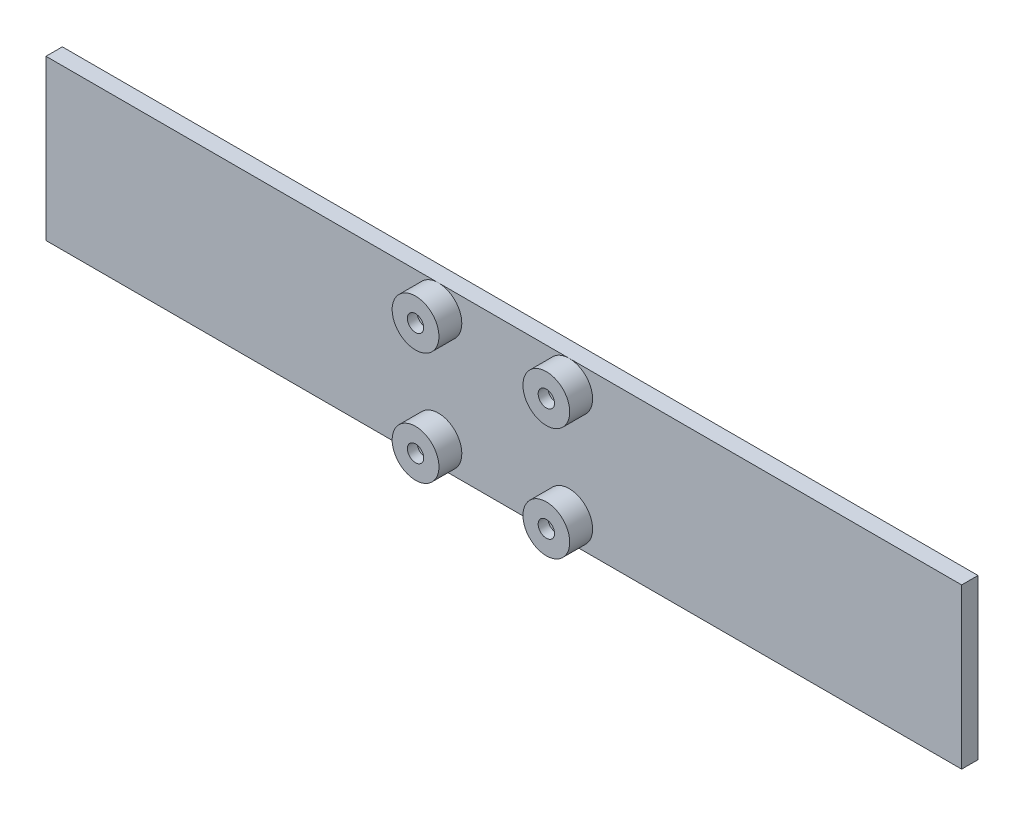
from build123d import *

# Parameters (mm, degrees)
SKETCH1_W           = 280
SKETCH1_H           = 48.8
BOSS_EXTRUDE1_DEPTH = 4
CUT_EXTRUDE1_DEPTH  = 5
SKETCH3_R           = 7.15
SKETCH3_R_2         = 5.25
BOSS_EXTRUDE2_DEPTH = 8
SKETCH4_R           = 7.15
SKETCH4_R_2         = 2.5
BOSS_EXTRUDE3_DEPTH = 3
SKETCH5_W           = 280
SKETCH5_H           = 48.8
BOSS_EXTRUDE6_DEPTH = 1
SKETCH6_R           = 5.25
CUT_EXTRUDE2_DEPTH  = 1


with BuildPart() as part:
    # Sketch1 → Boss-Extrude1 (new body)
    with BuildSketch(Plane.XY):
        with Locations((18.41484, 11.367285)):
            Rectangle(SKETCH1_W, SKETCH1_H)
    extrude(amount=BOSS_EXTRUDE1_DEPTH)

    # Sketch2 → Cut-Extrude1 (cut, through all)
    with BuildSketch(Plane.XY.offset(4)):
        with BuildLine():
            Line((-1.58516, 23.367285), (-1.58516, 28.617285))
            Line((-1.58516, 28.617285), (3.66484, 28.617285))
            ThreePointArc((3.66484, 28.617285), (-5.297471, 32.329596), (-1.58516, 23.367285))
        make_face()
        with BuildLine():
            Line((3.66484, 28.617285), (-1.58516, 28.617285))
            Line((-1.58516, 28.617285), (-1.58516, 23.367285))
            ThreePointArc((-1.58516, 23.367285), (2.12715, 24.904974), (3.66484, 28.617285))
        make_face()
        with BuildLine():
            ThreePointArc((3.66484, -5.882715), (2.12715, -2.170404), (-1.58516, -0.632715))
            Line((-1.58516, -0.632715), (-1.58516, -5.882715))
            Line((-1.58516, -5.882715), (3.66484, -5.882715))
        make_face()
        with BuildLine():
            Line((-1.58516, -5.882715), (-1.58516, -0.632715))
            ThreePointArc((-1.58516, -0.632715), (-5.297471, -9.595026), (3.66484, -5.882715))
            Line((3.66484, -5.882715), (-1.58516, -5.882715))
        make_face()
        with BuildLine():
            ThreePointArc((43.66484, -5.882715), (42.12715, -2.170404), (38.41484, -0.632715))
            Line((38.41484, -0.632715), (38.41484, -5.882715))
            Line((38.41484, -5.882715), (33.16484, -5.882715))
            ThreePointArc((33.16484, -5.882715), (38.41484, -11.132715), (43.66484, -5.882715))
        make_face()
        with BuildLine():
            Line((38.41484, -5.882715), (38.41484, -0.632715))
            ThreePointArc((38.41484, -0.632715), (34.702529, -2.170404), (33.16484, -5.882715))
            Line((33.16484, -5.882715), (38.41484, -5.882715))
        make_face()
        with BuildLine():
            ThreePointArc((43.66484, 28.617285), (38.41484, 33.867285), (33.16484, 28.617285))
            Line((33.16484, 28.617285), (38.41484, 28.617285))
            Line((38.41484, 28.617285), (38.41484, 23.367285))
            ThreePointArc((38.41484, 23.367285), (42.12715, 24.904974), (43.66484, 28.617285))
        make_face()
        with BuildLine():
            Line((38.41484, 28.617285), (33.16484, 28.617285))
            ThreePointArc((33.16484, 28.617285), (34.702529, 24.904974), (38.41484, 23.367285))
            Line((38.41484, 23.367285), (38.41484, 28.617285))
        make_face()
    extrude(amount=-CUT_EXTRUDE1_DEPTH, mode=Mode.SUBTRACT)

    # Sketch3 → Boss-Extrude2 (add)
    with BuildSketch(Plane.XY.offset(4)):
        with Locations((-1.58516, 28.617285)):
            Circle(SKETCH3_R)
        with Locations((-1.58516, 28.617285)):
            Circle(SKETCH3_R_2, mode=Mode.SUBTRACT)
        with Locations((38.41484, 28.617285)):
            Circle(SKETCH3_R)
        with Locations((38.41484, 28.617285)):
            Circle(SKETCH3_R_2, mode=Mode.SUBTRACT)
        with Locations((-1.58516, -5.882715)):
            Circle(SKETCH3_R)
        with Locations((-1.58516, -5.882715)):
            Circle(SKETCH3_R_2, mode=Mode.SUBTRACT)
        with Locations((38.41484, -5.882715)):
            Circle(SKETCH3_R)
        with Locations((38.41484, -5.882715)):
            Circle(SKETCH3_R_2, mode=Mode.SUBTRACT)
    extrude(amount=BOSS_EXTRUDE2_DEPTH)

    # Sketch4 → Boss-Extrude3 (add)
    with BuildSketch(Plane.XY.offset(12)):
        with Locations((-1.58516, 28.617285)):
            Circle(SKETCH4_R)
        with Locations((-1.58516, 28.617285)):
            Circle(SKETCH4_R_2, mode=Mode.SUBTRACT)
        with Locations((38.41484, 28.617285)):
            Circle(SKETCH4_R)
        with Locations((38.41484, 28.617285)):
            Circle(SKETCH4_R_2, mode=Mode.SUBTRACT)
        with Locations((-1.58516, -5.882715)):
            Circle(SKETCH4_R)
        with Locations((-1.58516, -5.882715)):
            Circle(SKETCH4_R_2, mode=Mode.SUBTRACT)
        with Locations((38.41484, -5.882715)):
            Circle(SKETCH4_R)
        with Locations((38.41484, -5.882715)):
            Circle(SKETCH4_R_2, mode=Mode.SUBTRACT)
    extrude(amount=-BOSS_EXTRUDE3_DEPTH)

    # Sketch5 → Boss-Extrude6 (add)
    with BuildSketch(Plane.XY.offset(4)):
        with Locations((18.41484, 11.367285)):
            Rectangle(SKETCH5_W, SKETCH5_H)
    extrude(amount=BOSS_EXTRUDE6_DEPTH)

    # Sketch6 → Cut-Extrude2 (cut)
    with BuildSketch(Plane(origin=(0, 0, 4), x_dir=(-1, 0, 0), z_dir=(0, 0, -1))):
        with Locations((-38.41484, 28.617285)):
            Circle(SKETCH6_R)
        with Locations((1.58516, 28.617285)):
            Circle(SKETCH6_R)
        with Locations((1.58516, -5.882715)):
            Circle(SKETCH6_R)
        with Locations((-38.41484, -5.882715)):
            Circle(SKETCH6_R)
    extrude(amount=-CUT_EXTRUDE2_DEPTH, mode=Mode.SUBTRACT)


solid = part.part
